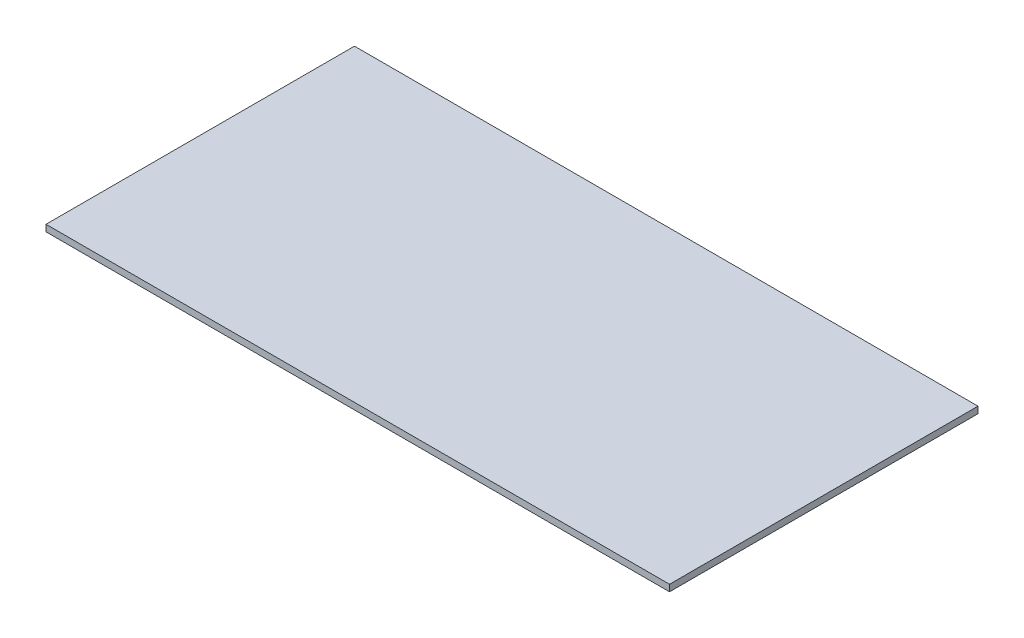
from build123d import *

# Parameters (mm, degrees)
SKETCH1_W           = 285
SKETCH1_H           = 141
BOSS_EXTRUDE1_DEPTH = 3


with BuildPart() as part:
    # Sketch1 → Boss-Extrude1 (new body)
    with BuildSketch(Plane(origin=(0, 0, 0), x_dir=(-1, 0, 0), z_dir=(0, 1, 0))):
        Rectangle(SKETCH1_W, SKETCH1_H)
    extrude(amount=BOSS_EXTRUDE1_DEPTH)


solid = part.part
